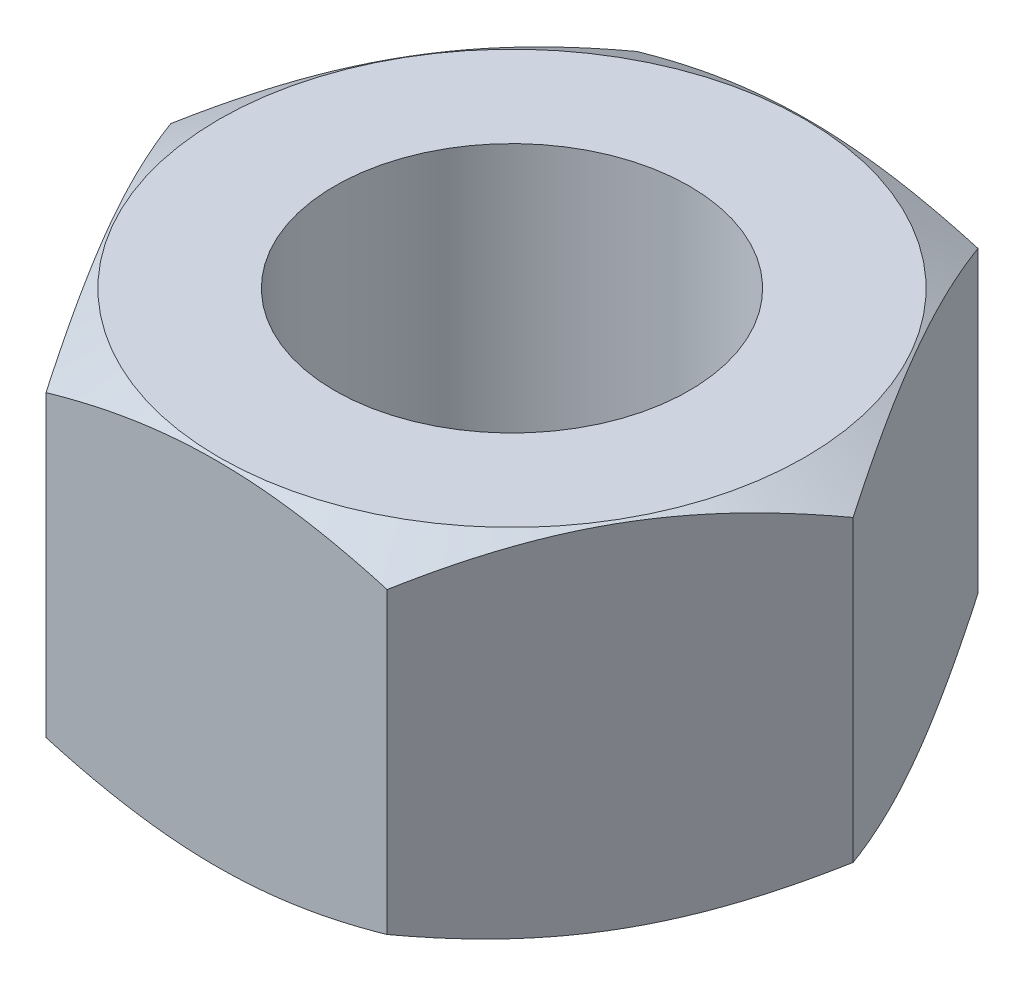
from build123d import *

# Parameters (mm, degrees)
SKETCH1_R           = 4.5
BOSS_EXTRUDE1_DEPTH = 4.5


with BuildPart() as part:
    # Sketch1 → Boss-Extrude1 (new body, symmetric)
    with BuildSketch(Plane(origin=(0, 0, 0), x_dir=(1, 0, 0), z_dir=(0, 1, 0))):
        Polygon((8.660254038, 0), (4.330127019, 7.5), (-4.330127019, 7.5), (-8.660254038, 0), (-4.330127019, -7.5), (4.330127019, -7.5), align=None)
        with Locations(Location((0, 0, 0), (0, 0, 270))):  # turned: the seam where the file's is
            Circle(SKETCH1_R, mode=Mode.SUBTRACT)
    extrude(amount=BOSS_EXTRUDE1_DEPTH, both=True)

    # Sketch3 → Cut-Revolve2 (revolve, cut)
    with BuildSketch(Plane(origin=(0, 0, 0), x_dir=(0, 0, -1), z_dir=(1, 0, 0)), mode=Mode.PRIVATE) as cut_revolve2_sk:
        Polygon((4.215565438, 6.358242553), (9.417491766, 3.354908986), (9.417491766, 6.358242553), align=None)
        Polygon((9.417491766, -6.358242553), (4.215565438, -6.358242553), (9.417491766, -3.354908986), align=None)
    revolve(cut_revolve2_sk.sketch.rotate(Axis((0, 0, 0), (0, 1, 0)), 180), axis=Axis((0, 0, 0), (0, 1, 0)), mode=Mode.SUBTRACT)  # turned: the seam where the file's is

    # Sketch2 → Cut-Revolve1 (revolve, cut)
    with BuildSketch(Plane.XY, mode=Mode.PRIVATE) as cut_revolve1_sk:
        Polygon((4.548999988, 6.358242553), (10.760780108, 2.771869628), (10.760780108, 6.358242553), align=None)
        Polygon((10.760780108, -6.358242553), (4.548999988, -6.358242553), (10.760780108, -2.771869628), align=None)
    revolve(cut_revolve1_sk.sketch.rotate(Axis((0, 0, 0), (0, 1, 0)), 270), axis=Axis((0, 0, 0), (0, 1, 0)), mode=Mode.SUBTRACT)  # turned: the seam where the file's is


solid = part.part
